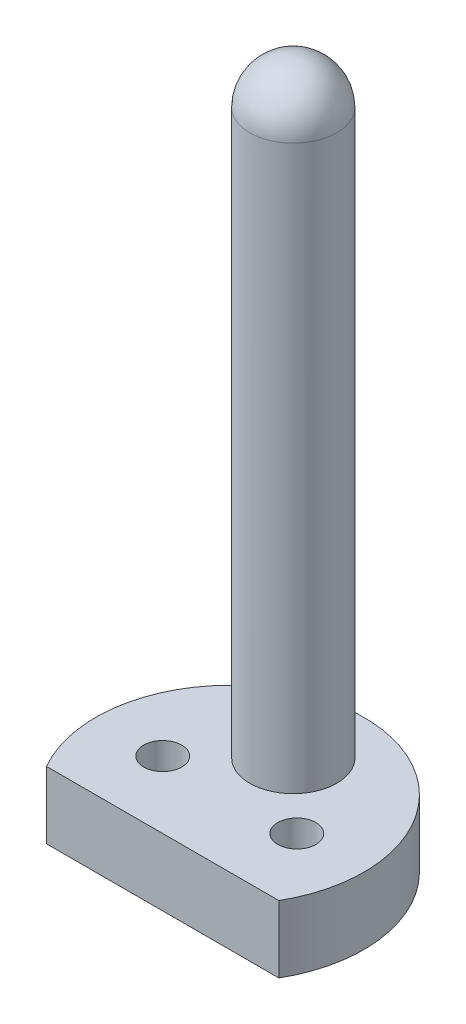
from build123d import *
from build123d.topology import SkipClean

# Parameters (mm, degrees)
SKETCH1_R           = 1.42
BOSS_EXTRUDE1_DEPTH = 5
SKETCH3_R           = 3.25
BOSS_EXTRUDE2_DEPTH = 42


with BuildPart() as part:
    # Sketch1 → Boss-Extrude1 (new body)
    with BuildSketch(Plane(origin=(0, 0, 0), x_dir=(1, 0, 0), z_dir=(0, 1, 0))):
        with BuildLine():
            Line((-8.660254038, -5), (8.660254038, -5))
            ThreePointArc((8.660254038, -5), (0, 10), (-8.660254038, -5))
        make_face()
        with Locations(Location((-5, 0, 0), (0, 0, 270))):
            Circle(SKETCH1_R, mode=Mode.SUBTRACT)
        with Locations(Location((5, 0, 0), (0, 0, 270))):
            Circle(SKETCH1_R, mode=Mode.SUBTRACT)
    extrude(amount=BOSS_EXTRUDE1_DEPTH)

    # Sketch3 → Boss-Extrude2 (add)
    with BuildSketch(Plane(origin=(0, 5, 0), x_dir=(1, 0, 0), z_dir=(0, 1, 0))):
        with Locations(Location((0, 4.734782237, 0), (0, 0, 90))):
            Circle(SKETCH3_R)
    extrude(amount=BOSS_EXTRUDE2_DEPTH)

    # Sketch6 → Revolve1 (revolve)
    with SkipClean():  # the faces are left unmerged after this step: merging them gives an invalid solid
        with BuildSketch(Plane(origin=(0, 47, 0), x_dir=(1, 0, 0), z_dir=(0, 1, 0))):
            with BuildLine():
                ThreePointArc((3.25, 4.734782237), (2.298097039, 7.032879276), (0, 7.984782237))
                Line((0, 7.984782237), (0, 1.484782237))
                ThreePointArc((0, 1.484782237), (2.298097039, 2.436685198), (3.25, 4.734782237))
            make_face()
            with BuildLine():
                Line((0, 1.484782237), (0, 7.984782237))
                ThreePointArc((0, 7.984782237), (-3.25, 4.734782237), (0, 1.484782237))
            make_face()
        revolve(axis=Axis((0, 47, -7.984782237), (0, 0, 1)))


solid = part.part
